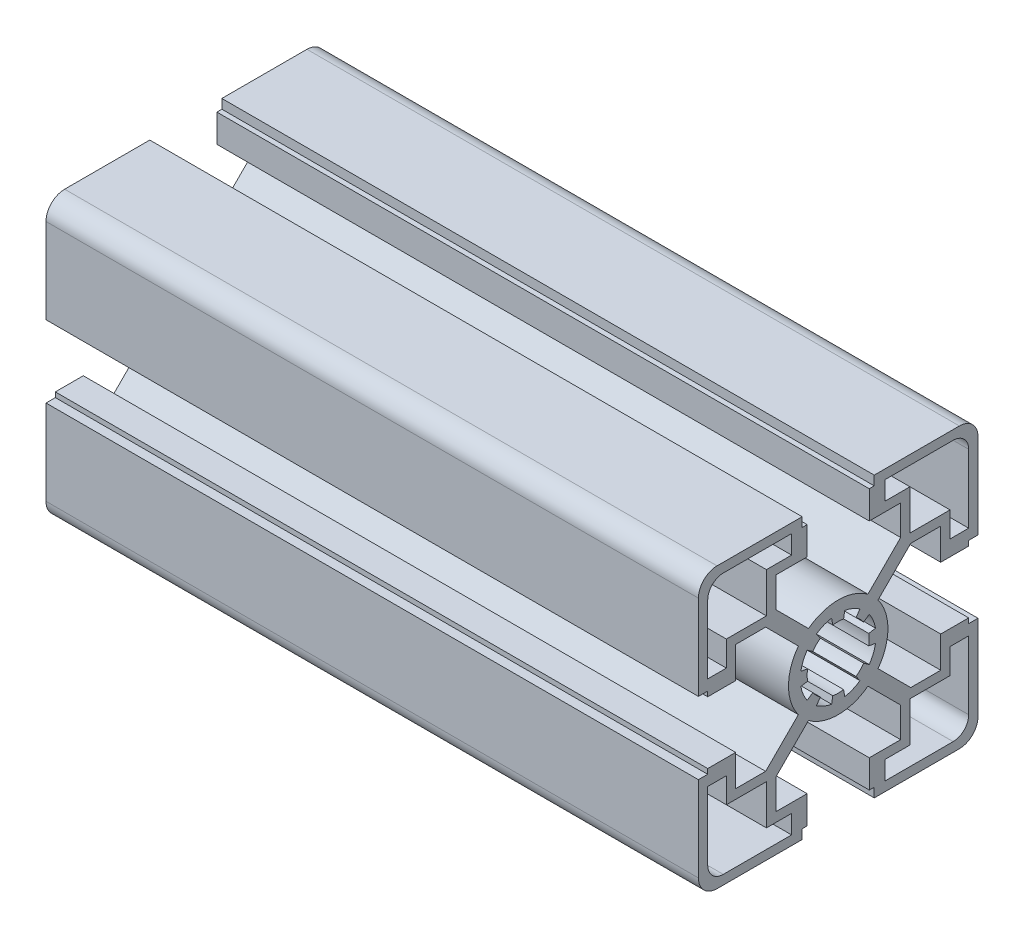
from build123d import *

# Parameters (mm, degrees)
BR_EXTRUDE_DEPTH      = 52.5
BR_EXTRUDE_DEPTH_BACK = 52.5


with BuildPart() as part:
    # Sketch2 → BR_Extrude (new body, two sides)
    with BuildSketch(Plane(origin=(0, 0, 0), x_dir=(0, 0, -1), z_dir=(1, 0, 0))) as br_extrude_sk:
        with BuildLine():
            Line((-10.05, 11.676345597), (-10.05, 16.5))
            Line((-10.05, 16.5), (-5, 16.5))
            Line((-5, 16.5), (-5, 21))
            Line((-5, 21), (-5.8, 21))
            Line((-5.8, 21), (-5.8, 22.5))
            Line((-5.8, 22.5), (-19.5, 22.5))
            ThreePointArc((-19.5, 22.5), (-21.621320344, 21.621320344), (-22.5, 19.5))
            Line((-22.5, 19.5), (-22.5, 5.8))
            Line((-22.5, 5.8), (-21, 5.8))
            Line((-21, 5.8), (-21, 5))
            Line((-21, 5), (-16.5, 5))
            Line((-16.5, 5), (-16.5, 10.05))
            Line((-16.5, 10.05), (-11.676345597, 10.05))
            Line((-11.676345597, 10.05), (-6.411275155, 4.784929559))
            ThreePointArc((-6.411275155, 4.784929559), (-8, 0), (-6.411275155, -4.784929559))
            Line((-6.411275155, -4.784929559), (-11.676345597, -10.05))
            Line((-11.676345597, -10.05), (-16.5, -10.05))
            Line((-16.5, -10.05), (-16.5, -5))
            Line((-16.5, -5), (-21, -5))
            Line((-21, -5), (-21, -5.8))
            Line((-21, -5.8), (-22.5, -5.8))
            Line((-22.5, -5.8), (-22.5, -19.5))
            ThreePointArc((-22.5, -19.5), (-21.621320344, -21.621320344), (-19.5, -22.5))
            Line((-19.5, -22.5), (-5.8, -22.5))
            Line((-5.8, -22.5), (-5.8, -21))
            Line((-5.8, -21), (-5, -21))
            Line((-5, -21), (-5, -16.5))
            Line((-5, -16.5), (-10.05, -16.5))
            Line((-10.05, -16.5), (-10.05, -11.676345597))
            Line((-10.05, -11.676345597), (-4.784929559, -6.411275155))
            ThreePointArc((-4.784929559, -6.411275155), (0, -8), (4.784929559, -6.411275155))
            Line((4.784929559, -6.411275155), (10.05, -11.676345597))
            Line((10.05, -11.676345597), (10.05, -16.5))
            Line((10.05, -16.5), (5, -16.5))
            Line((5, -16.5), (5, -21))
            Line((5, -21), (5.8, -21))
            Line((5.8, -21), (5.8, -22.5))
            Line((5.8, -22.5), (19.5, -22.5))
            ThreePointArc((19.5, -22.5), (21.621320344, -21.621320344), (22.5, -19.5))
            Line((22.5, -19.5), (22.5, -5.8))
            Line((22.5, -5.8), (21, -5.8))
            Line((21, -5.8), (21, -5))
            Line((21, -5), (16.5, -5))
            Line((16.5, -5), (16.5, -10.05))
            Line((16.5, -10.05), (11.676345597, -10.05))
            Line((11.676345597, -10.05), (6.411275155, -4.784929559))
            ThreePointArc((6.411275155, -4.784929559), (8, 0), (6.411275155, 4.784929559))
            Line((6.411275155, 4.784929559), (11.676345597, 10.05))
            Line((11.676345597, 10.05), (16.5, 10.05))
            Line((16.5, 10.05), (16.5, 5))
            Line((16.5, 5), (21, 5))
            Line((21, 5), (21, 5.8))
            Line((21, 5.8), (22.5, 5.8))
            Line((22.5, 5.8), (22.5, 19.5))
            ThreePointArc((22.5, 19.5), (21.621320344, 21.621320344), (19.5, 22.5))
            Line((19.5, 22.5), (5.8, 22.5))
            Line((5.8, 22.5), (5.8, 21))
            Line((5.8, 21), (5, 21))
            Line((5, 21), (5, 16.5))
            Line((5, 16.5), (10.05, 16.5))
            Line((10.05, 16.5), (10.05, 11.676345597))
            Line((10.05, 11.676345597), (4.784929559, 6.411275155))
            ThreePointArc((4.784929559, 6.411275155), (0, 8), (-4.784929559, 6.411275155))
            Line((-4.784929559, 6.411275155), (-10.05, 11.676345597))
        make_face()
        with BuildLine():
            Line((11.55, 11.55), (11.55, 18))
            Line((11.55, 18), (7.5, 18))
            Line((7.5, 18), (7.5, 21))
            Line((7.5, 21), (18.5, 21))
            ThreePointArc((18.5, 21), (20.267766953, 20.267766953), (21, 18.5))
            Line((21, 18.5), (21, 7.5))
            Line((21, 7.5), (18, 7.5))
            Line((18, 7.5), (18, 11.55))
            Line((18, 11.55), (11.55, 11.55))
        make_face(mode=Mode.SUBTRACT)
        with BuildLine():
            Line((11.55, -11.55), (18, -11.55))
            Line((18, -11.55), (18, -7.5))
            Line((18, -7.5), (21, -7.5))
            Line((21, -7.5), (21, -18.5))
            ThreePointArc((21, -18.5), (20.267766953, -20.267766953), (18.5, -21))
            Line((18.5, -21), (7.5, -21))
            Line((7.5, -21), (7.5, -18))
            Line((7.5, -18), (11.55, -18))
            Line((11.55, -18), (11.55, -11.55))
        make_face(mode=Mode.SUBTRACT)
        with BuildLine():
            Line((-11.55, 11.55), (-18, 11.55))
            Line((-18, 11.55), (-18, 7.5))
            Line((-18, 7.5), (-21, 7.5))
            Line((-21, 7.5), (-21, 18.5))
            ThreePointArc((-21, 18.5), (-20.267766953, 20.267766953), (-18.5, 21))
            Line((-18.5, 21), (-7.5, 21))
            Line((-7.5, 21), (-7.5, 18))
            Line((-7.5, 18), (-11.55, 18))
            Line((-11.55, 18), (-11.55, 11.55))
        make_face(mode=Mode.SUBTRACT)
        with BuildLine():
            Line((-11.55, -11.55), (-11.55, -18))
            Line((-11.55, -18), (-7.5, -18))
            Line((-7.5, -18), (-7.5, -21))
            Line((-7.5, -21), (-18.5, -21))
            ThreePointArc((-18.5, -21), (-20.267766953, -20.267766953), (-21, -18.5))
            Line((-21, -18.5), (-21, -7.5))
            Line((-21, -7.5), (-18, -7.5))
            Line((-18, -7.5), (-18, -11.55))
            Line((-18, -11.55), (-11.55, -11.55))
        make_face(mode=Mode.SUBTRACT)
        with BuildLine():
            Line((-6.007327293, -1.059253884), (-4.924038765, -0.868240888))
            ThreePointArc((-4.924038765, -0.868240888), (-5, 0), (-4.924038765, 0.868240888))
            Line((-4.924038765, 0.868240888), (-6.007327293, 1.059253884))
            ThreePointArc((-6.007327293, 1.059253884), (-5.635665148, 2.334368937), (-4.99682747, 3.498816262))
            Line((-4.99682747, 3.498816262), (-4.095760221, 2.867882182))
            ThreePointArc((-4.095760221, 2.867882182), (-3.535533906, 3.535533906), (-2.867882182, 4.095760221))
            Line((-2.867882182, 4.095760221), (-3.498816262, 4.99682747))
            ThreePointArc((-3.498816262, 4.99682747), (-2.334368937, 5.635665148), (-1.059253884, 6.007327293))
            Line((-1.059253884, 6.007327293), (-0.868240888, 4.924038765))
            ThreePointArc((-0.868240888, 4.924038765), (0, 5), (0.868240888, 4.924038765))
            Line((0.868240888, 4.924038765), (1.059253884, 6.007327293))
            ThreePointArc((1.059253884, 6.007327293), (2.334368937, 5.635665148), (3.498816262, 4.99682747))
            Line((3.498816262, 4.99682747), (2.867882182, 4.095760221))
            ThreePointArc((2.867882182, 4.095760221), (3.535533906, 3.535533906), (4.095760221, 2.867882182))
            Line((4.095760221, 2.867882182), (4.99682747, 3.498816262))
            ThreePointArc((4.99682747, 3.498816262), (5.635665148, 2.334368937), (6.007327293, 1.059253884))
            Line((6.007327293, 1.059253884), (4.924038765, 0.868240888))
            ThreePointArc((4.924038765, 0.868240888), (5, 0), (4.924038765, -0.868240888))
            Line((4.924038765, -0.868240888), (6.007327293, -1.059253884))
            ThreePointArc((6.007327293, -1.059253884), (5.635665148, -2.334368937), (4.99682747, -3.498816262))
            Line((4.99682747, -3.498816262), (4.095760221, -2.867882182))
            ThreePointArc((4.095760221, -2.867882182), (3.535533906, -3.535533906), (2.867882182, -4.095760221))
            Line((2.867882182, -4.095760221), (3.498816262, -4.99682747))
            ThreePointArc((3.498816262, -4.99682747), (2.334368937, -5.635665148), (1.059253884, -6.007327293))
            Line((1.059253884, -6.007327293), (0.868240888, -4.924038765))
            ThreePointArc((0.868240888, -4.924038765), (0, -5), (-0.868240888, -4.924038765))
            Line((-0.868240888, -4.924038765), (-1.059253884, -6.007327293))
            ThreePointArc((-1.059253884, -6.007327293), (-2.334368937, -5.635665148), (-3.498816262, -4.99682747))
            Line((-3.498816262, -4.99682747), (-2.867882182, -4.095760221))
            ThreePointArc((-2.867882182, -4.095760221), (-3.535533906, -3.535533906), (-4.095760221, -2.867882182))
            Line((-4.095760221, -2.867882182), (-4.99682747, -3.498816262))
            ThreePointArc((-4.99682747, -3.498816262), (-5.635665148, -2.334368937), (-6.007327293, -1.059253884))
        make_face(mode=Mode.SUBTRACT)
    extrude(amount=BR_EXTRUDE_DEPTH)
    extrude(br_extrude_sk.sketch, amount=-BR_EXTRUDE_DEPTH_BACK)


solid = part.part
